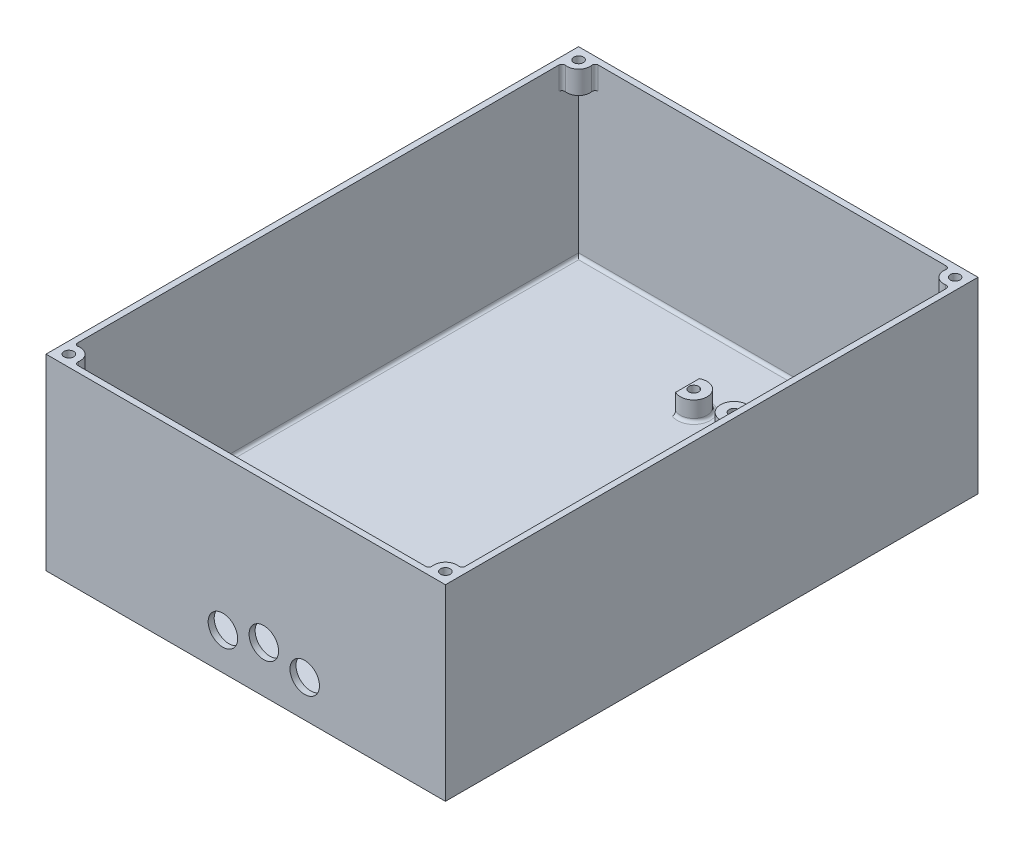
from build123d import *

# Parameters (mm, degrees)
SKETCH2_W                                = 203.2
SKETCH2_H                                = 273.05
BOX_BASE_DEPTH                           = 6.35
SKETCH2_3_W                              = 209.55
SKETCH2_3_H                              = 279.4
SKETCH2_3_W_2                            = 203.2
SKETCH2_3_H_2                            = 273.05
BOX_WALL_HEIGHT_DEPTH                    = 98.425
SKETCH9_R                                = 2.5273
BOSS_EXTRUDE4_DEPTH                      = 12
FILLET2_R                                = 1.5875
LID_MOUNTING_HEAT_SET_INSERT_HOLES_D     = 5.0546
LID_MOUNTING_HEAT_SET_INSERT_HOLES_DEPTH = 8.89
LID_MOUNTING_HEAT_SET_INSERT_HOLES_TIP   = 1.518555042
SKETCH14_R                               = 2.5273
MME_42_MOUNTING_PEGS_DEPTH               = 10
FILLET3_R                                = 1.5875
FILLET5_R                                = 1.5875
SKETCH19_R                               = 7.7390625
CUT_EXTRUDE2_DEPTH                       = 3.175


with BuildPart() as part:
    # Sketch2 → Box Base (new body)
    with BuildSketch(Plane(origin=(0, 0, 0), x_dir=(1, 0, 0), z_dir=(0, 1, 0))):
        Rectangle(SKETCH2_W, SKETCH2_H)
    extrude(amount=BOX_BASE_DEPTH)

    # Sketch2_3 → Box Wall height (add)
    with BuildSketch(Plane(origin=(0, 0, 0), x_dir=(1, 0, 0), z_dir=(0, 1, 0))):
        Rectangle(SKETCH2_3_W, SKETCH2_3_H)
        Rectangle(SKETCH2_3_W_2, SKETCH2_3_H_2, mode=Mode.SUBTRACT)
    extrude(amount=BOX_WALL_HEIGHT_DEPTH)

    # Sketch9 → Boss-Extrude4 (add)
    with BuildSketch(Plane(origin=(0, 98.425, 0), x_dir=(1, 0, 0), z_dir=(0, 1, 0))):
        with BuildLine():
            ThreePointArc((-93.481666929, -136.525), (-94.532359313, -129.457359313), (-101.6, -128.406666929))
            Line((-101.6, -128.406666929), (-101.6, -136.525))
            Line((-101.6, -136.525), (-93.481666929, -136.525))
        make_face()
        with Locations((-98.775, -133.7)):
            Circle(SKETCH9_R, mode=Mode.SUBTRACT)
        with Locations((-98.775, -133.7)):
            Circle(SKETCH9_R)
        Polygon((-101.6, -136.525), (-101.6, -128.406666929), (-104.775, -128.406666929), (-104.775, -139.7), (-93.481666929, -139.7), (-93.481666929, -136.525), align=None)
        with BuildLine():
            ThreePointArc((101.6, -128.406666929), (94.532359313, -129.457359313), (93.481666929, -136.525))
            Line((93.481666929, -136.525), (101.6, -136.525))
            Line((101.6, -136.525), (101.6, -128.406666929))
        make_face()
        with Locations((98.775, -133.7)):
            Circle(SKETCH9_R, mode=Mode.SUBTRACT)
        with Locations((98.775, -133.7)):
            Circle(SKETCH9_R)
        Polygon((101.6, -136.525), (93.481666929, -136.525), (93.481666929, -139.7), (104.775, -139.7), (104.775, -128.406666929), (101.6, -128.406666929), align=None)
        Polygon((93.481666929, 139.7), (93.481666929, 136.525), (101.6, 136.525), (101.6, 128.406666929), (104.775, 128.406666929), (104.775, 139.7), align=None)
        with BuildLine():
            Line((101.6, 136.525), (93.481666929, 136.525))
            ThreePointArc((93.481666929, 136.525), (94.532359313, 129.457359313), (101.6, 128.406666929))
            Line((101.6, 128.406666929), (101.6, 136.525))
        make_face()
        with Locations((98.775, 133.7)):
            Circle(SKETCH9_R, mode=Mode.SUBTRACT)
        with Locations((98.775, 133.7)):
            Circle(SKETCH9_R)
        with BuildLine():
            Line((-101.6, 136.525), (-101.6, 128.406666929))
            ThreePointArc((-101.6, 128.406666929), (-94.532359313, 129.457359313), (-93.481666929, 136.525))
            Line((-93.481666929, 136.525), (-101.6, 136.525))
        make_face()
        with Locations((-98.775, 133.7)):
            Circle(SKETCH9_R, mode=Mode.SUBTRACT)
        with Locations((-98.775, 133.7)):
            Circle(SKETCH9_R)
        Polygon((-104.775, 128.406666929), (-101.6, 128.406666929), (-101.6, 136.525), (-93.481666929, 136.525), (-93.481666929, 139.7), (-104.775, 139.7), align=None)
    extrude(amount=-BOSS_EXTRUDE4_DEPTH)

    # Fillet2
    fillet2_edges = [part.edges().sort_by_distance(p)[0] for p in [
        (-93.481666929, 92.425, -136.525),
        (-101.6, 92.425, -128.406666929),
        (-93.481666929, 92.425, 136.525),
        (-101.6, 92.425, 128.406666929),
        (93.481666929, 92.425, 136.525),
        (101.6, 92.425, 128.406666929),
        (101.6, 92.425, -128.406666929),
        (93.481666929, 92.425, -136.525),
    ]]
    fillet(fillet2_edges, radius=FILLET2_R)

    # Lid Mounting heat Set Insert Holes
    with Locations(Plane(origin=(0, 98.425, 0), x_dir=(1, 0, 0), z_dir=(0, 1, 0))):
        with Locations((98.775, 133.7), (-98.775, 133.7), (-98.775, -133.7), (98.775, -133.7)):
            Hole(LID_MOUNTING_HEAT_SET_INSERT_HOLES_D / 2, depth=LID_MOUNTING_HEAT_SET_INSERT_HOLES_DEPTH)
            with Locations((0, 0, -(LID_MOUNTING_HEAT_SET_INSERT_HOLES_DEPTH + LID_MOUNTING_HEAT_SET_INSERT_HOLES_TIP / 2))):  # 118° drill point
                Cone(0, LID_MOUNTING_HEAT_SET_INSERT_HOLES_D / 2, LID_MOUNTING_HEAT_SET_INSERT_HOLES_TIP, mode=Mode.SUBTRACT)

    # Sketch14 → MME-42 Mounting Pegs (add)
    with BuildSketch(Plane(origin=(0, 6.35, 0), x_dir=(1, 0, 0), z_dir=(0, 1, 0))):
        with BuildLine():
            Line((-4.343000027, -91.236739798), (-4.343000027, -103.581260202))
            ThreePointArc((-4.343000027, -103.581260202), (5.958999973, -97.409), (-4.343000027, -91.236739798))
        make_face()
        with Locations(Location((-1.041000027, -97.409, 0), (0, 0, 270))):
            Circle(SKETCH14_R, mode=Mode.SUBTRACT)
        with BuildLine():
            ThreePointArc((23.342999973, -91.236739798), (13.040999973, -97.409), (23.342999973, -103.581260202))
            Line((23.342999973, -103.581260202), (23.342999973, -91.236739798))
        make_face()
        with Locations(Location((20.040999973, -97.409, 0), (0, 0, 270))):
            Circle(SKETCH14_R, mode=Mode.SUBTRACT)
        with BuildLine():
            Line((-4.343000027, 102.565260202), (-4.343000027, 90.220739798))
            ThreePointArc((-4.343000027, 90.220739798), (5.958999973, 96.393), (-4.343000027, 102.565260202))
        make_face()
        with Locations(Location((-1.041000027, 96.393, 0), (0, 0, 270))):
            Circle(SKETCH14_R, mode=Mode.SUBTRACT)
        with BuildLine():
            ThreePointArc((23.342999973, 102.565260202), (13.040999973, 96.393), (23.342999973, 90.220739798))
            Line((23.342999973, 90.220739798), (23.342999973, 102.565260202))
        make_face()
        with Locations(Location((20.040999973, 96.393, 0), (0, 0, 270))):
            Circle(SKETCH14_R, mode=Mode.SUBTRACT)
    extrude(amount=MME_42_MOUNTING_PEGS_DEPTH)

    # Fillet3
    fillet3_edges = [part.edges().sort_by_distance(p)[0] for p in [
        (5.958999973, 6.35, 97.409),
        (13.040999973, 6.35, 97.409),
        (5.958999973, 6.35, -96.393),
        (13.040999973, 6.35, -96.393),
    ]]
    fillet(fillet3_edges, radius=FILLET3_R)

    # Fillet5
    fillet5_edges = [part.edges().sort_by_distance(p)[0] for p in [
        (0, 6.35, 136.525),
        (101.6, 6.35, 0),
        (0, 6.35, -136.525),
        (-101.6, 6.35, 0),
    ]]
    fillet(fillet5_edges, radius=FILLET5_R)

    # Sketch19 → Cut-Extrude2 (cut)
    with BuildSketch(Plane.XY.offset(139.7)):
        with Locations((-11.963000027, 19.398)):
            Circle(SKETCH19_R)
        with Locations((9.499999973, 24.478)):
            Circle(SKETCH19_R)
        with Locations((30.962999973, 19.398)):
            Circle(SKETCH19_R)
    extrude(amount=-CUT_EXTRUDE2_DEPTH, mode=Mode.SUBTRACT)


solid = part.part
